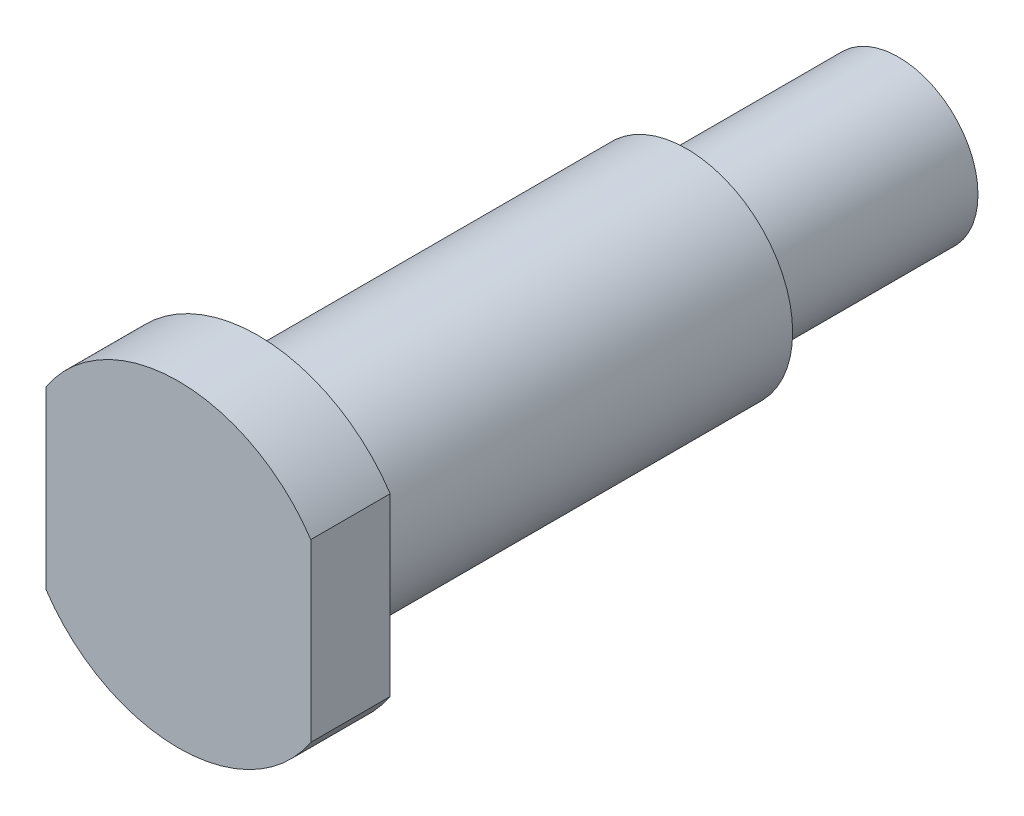
from build123d import *

# Parameters (mm, degrees)
SKETCH_3_OUTSIDE_W   = 20.412
SKETCH_3_OUTSIDE_H   = 20.412
SKETCH_3_OUTSIDE_W_2 = 10
SKETCH_3_OUTSIDE_H_2 = 13.079471602
CUT_EXTRUDE_1_DEPTH  = 10


with BuildPart() as part:
    # 草图2 → 旋转1 (revolve)
    with BuildSketch(Plane(origin=(0, 0, 0), x_dir=(0, 0, -1), z_dir=(1, 0, 0))):
        Polygon((0, 0), (0, 6), (3, 6), (3, 4), (19.2, 4), (19.2, 3), (27.2, 3), (27.2, 0), align=None)
    revolve(axis=Axis((0, 0, 0), (0, 0, -1)))

    # 草图3 outside → 切除-拉伸1 (cut)
    with BuildSketch(Plane.XY):
        Rectangle(SKETCH_3_OUTSIDE_W, SKETCH_3_OUTSIDE_H)
        Rectangle(SKETCH_3_OUTSIDE_W_2, SKETCH_3_OUTSIDE_H_2, mode=Mode.SUBTRACT)
    extrude(amount=-CUT_EXTRUDE_1_DEPTH, mode=Mode.SUBTRACT)


solid = part.part
